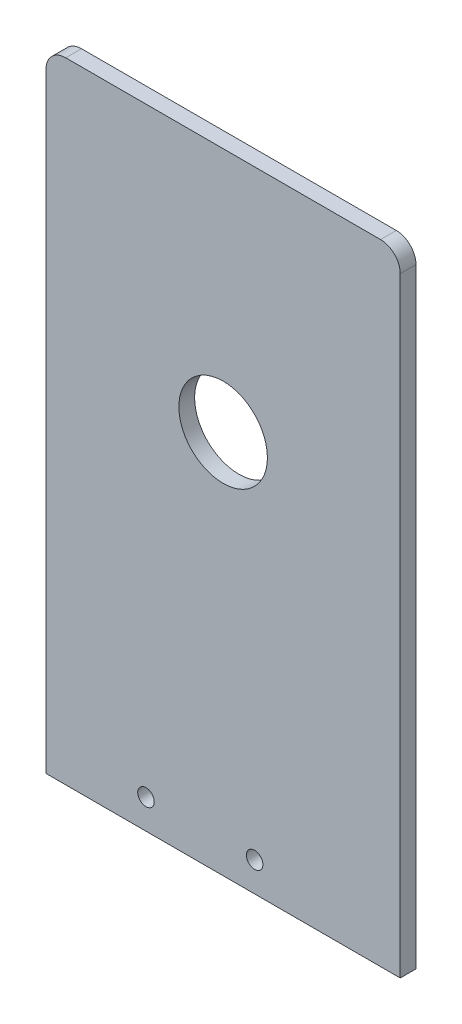
from build123d import *

# Parameters (mm, degrees)
SKETCH1_W           = 114.3
SKETCH1_H           = 203.2
BOSS_EXTRUDE1_DEPTH = 5.08
FILLET1_R           = 6.35
SKETCH3_R           = 14.2875
CUT_EXTRUDE1_DEPTH  = 5.08
SKETCH4_R           = 2.667
CUT_EXTRUDE2_DEPTH  = 5.08


with BuildPart() as part:
    # Sketch1 → Boss-Extrude1 (new body)
    with BuildSketch(Plane.XY):
        Rectangle(SKETCH1_W, SKETCH1_H)
    extrude(amount=BOSS_EXTRUDE1_DEPTH)

    # Fillet1
    fillet1_edges = [part.edges().sort_by_distance(p)[0] for p in [
        (-57.15, 101.6, 2.54),
        (57.15, 101.6, 2.54),
    ]]
    fillet(fillet1_edges, radius=FILLET1_R)

    # Sketch3 → Cut-Extrude1 (cut)
    with BuildSketch(Plane.XY.offset(5.08)):
        with Locations((0, 22.352)):
            Circle(SKETCH3_R)
    extrude(amount=-CUT_EXTRUDE1_DEPTH, mode=Mode.SUBTRACT)

    # Sketch4 → Cut-Extrude2 (cut)
    with BuildSketch(Plane.XY.offset(5.08)):
        with Locations((10.16, -92.075)):
            Circle(SKETCH4_R)
        with Locations((-24.892, -92.075)):
            Circle(SKETCH4_R)
    extrude(amount=-CUT_EXTRUDE2_DEPTH, mode=Mode.SUBTRACT)


solid = part.part
